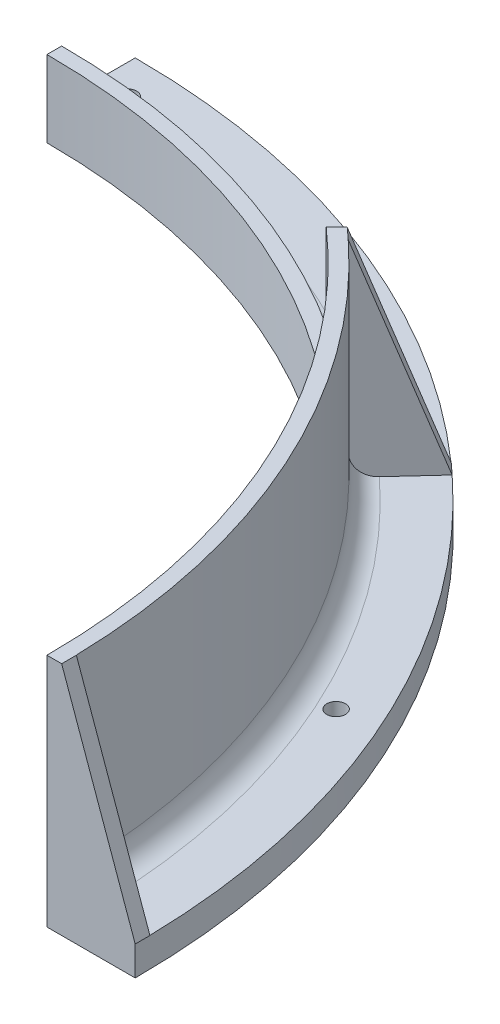
from build123d import *

# Parameters (mm, degrees)
BOSS_EXTRUDE1_DEPTH        = 6.35
BOSS_EXTRUDE2_DEPTH        = 44.45
CUT_EXTRUDE1_DEPTH         = 34.29
F_10_32_TAPPED_HOLE1_D     = 4.0386
F_10_32_TAPPED_HOLE1_DEPTH = 6.35
BOSS_EXTRUDE3_DEPTH        = 3.175
CIRPATTERN1_COUNT          = 2
CIRPATTERN1_ANGLE          = 47.375
FILLET1_R                  = 4.7625


with BuildPart() as part:
    # Sketch1 → Boss-Extrude1 (new body)
    with BuildSketch(Plane(origin=(0, 0, 0), x_dir=(1, 0, 0), z_dir=(0, 1, 0))):
        with BuildLine():
            Line((165.608, 0), (146.558, 0))
            ThreePointArc((146.558, 0), (103.632155637, -103.632155637), (0, -146.558))
            Line((0, -146.558), (0, -165.608))
            ThreePointArc((0, -165.608), (117.102539819, -117.102539819), (165.608, 0))
        make_face()
    extrude(amount=BOSS_EXTRUDE1_DEPTH)

    # Sketch2 → Boss-Extrude2 (add)
    with BuildSketch(Plane(origin=(0, 6.35, 0), x_dir=(1, 0, 0), z_dir=(0, 1, 0))):
        with BuildLine():
            Line((146.558, 0), (149.733, 0))
            ThreePointArc((149.733, 0), (105.877219667, -105.877219667), (0, -149.733))
            Line((0, -149.733), (0, -146.558))
            ThreePointArc((0, -146.558), (103.632155637, -103.632155637), (146.558, 0))
        make_face()
    extrude(amount=BOSS_EXTRUDE2_DEPTH)

    # Sketch3 → Cut-Extrude1 (cut)
    with BuildSketch(Plane(origin=(0, 50.8, 0), x_dir=(1, 0, 0), z_dir=(0, 1, 0))):
        with BuildLine():
            Line((96.677867382, -110.148251563), (98.927586748, -112.39797093))
            ThreePointArc((98.927586748, -112.39797093), (52.869111529, -140.088644562), (0, -149.733))
            Line((0, -149.733), (0, -146.558))
            ThreePointArc((0, -146.558), (51.65336345, -137.153845766), (96.677867382, -110.148251563))
        make_face()
    extrude(amount=-CUT_EXTRUDE1_DEPTH, mode=Mode.SUBTRACT)

    # #10-32 Tapped Hole1
    with Locations(Plane(origin=(0, 6.35, 0), x_dir=(1, 0, 0), z_dir=(0, 1, 0))):
        with Locations((6.35, -157.542578595), (87.858258413, -130.923309609), (143.383000088, -65.58431105)):
            Hole(F_10_32_TAPPED_HOLE1_D / 2, depth=F_10_32_TAPPED_HOLE1_DEPTH)

    # Sketch9 → Boss-Extrude3 (add)
    with BuildSketch(Plane(origin=(0, 0, 0), x_dir=(-1, 0, 0), z_dir=(0, 0, -1))):
        Polygon((-165.608, 6.35), (-149.733, 50.8), (-146.558, 50.8), (-146.558, 6.35), align=None)
    boss_extrude3 = extrude(amount=-BOSS_EXTRUDE3_DEPTH)

    # CirPattern1: Boss-Extrude3 ×2 about axis
    cirpattern1_axis = Axis((0, 0, 0), (0, -1, 0))
    for i in range(1, CIRPATTERN1_COUNT):
        add(boss_extrude3.rotate(cirpattern1_axis, i * CIRPATTERN1_ANGLE / (CIRPATTERN1_COUNT - 1)))

    # Fillet1
    fillet1_edges = [part.edges().sort_by_distance(p)[0] for p in [
        (52.939054251, 6.35, 140.062228399),
        (136.472515739, 6.35, 61.605387238),
    ]]
    fillet(fillet1_edges, radius=FILLET1_R)


with BuildPart() as body_2:
    # Mirror1: mirrored copy
    add(part.part.mirror(Plane.XY))


solid = body_2.part
